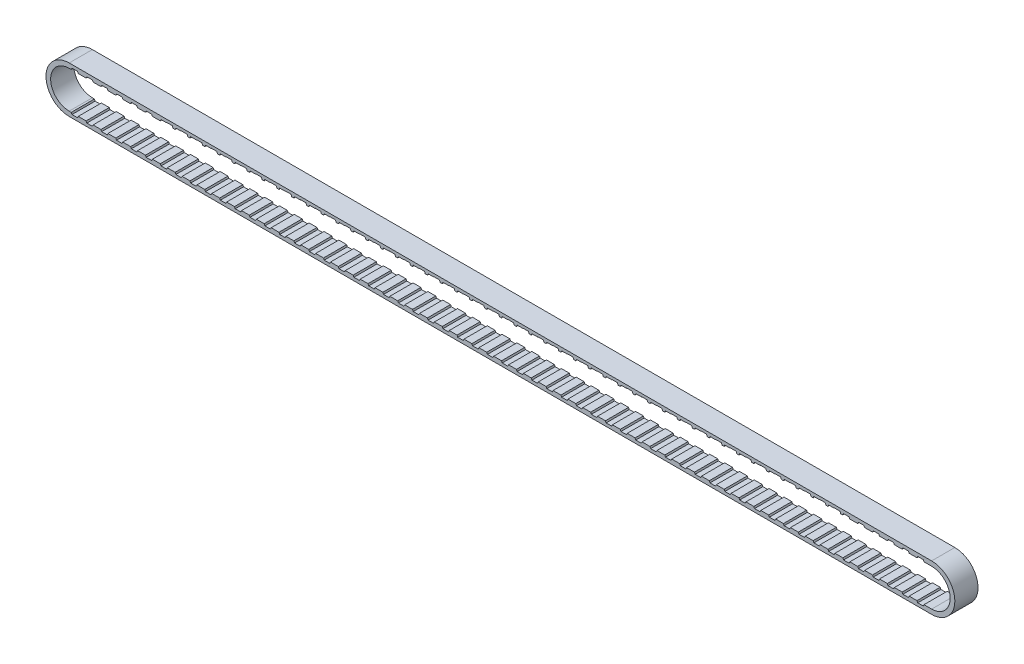
from build123d import *

# Parameters (mm, degrees)
BOSS_EXTRUDE1_DEPTH   = 6.35
CUT_EXTRUDE1_DEPTH    = 8.89
LPATTERN3_COUNT       = 50
LPATTERN3_PITCH       = 4.064
LPATTERN3_COL_COUNT   = 9
LPATTERN3_COL_PITCH   = 4.064
MIRROR3_COPY_1_DEPTH  = 8.89
MIRROR3_COPY_2_DEPTH  = 8.89
MIRROR3_COPY_3_DEPTH  = 8.89
MIRROR3_COPY_4_DEPTH  = 8.89
MIRROR3_COPY_5_DEPTH  = 8.89
MIRROR3_COPY_6_DEPTH  = 8.89
MIRROR3_COPY_7_DEPTH  = 8.89
MIRROR3_COPY_8_DEPTH  = 8.89
MIRROR3_COPY_9_DEPTH  = 8.89
MIRROR3_COPY_10_DEPTH = 8.89
MIRROR3_COPY_11_DEPTH = 8.89
MIRROR3_COPY_12_DEPTH = 8.89
MIRROR3_COPY_13_DEPTH = 8.89
MIRROR3_COPY_14_DEPTH = 8.89
MIRROR3_COPY_15_DEPTH = 8.89
MIRROR3_COPY_16_DEPTH = 8.89
MIRROR3_COPY_17_DEPTH = 8.89
MIRROR3_COPY_18_DEPTH = 8.89
MIRROR3_COPY_19_DEPTH = 8.89
MIRROR3_COPY_20_DEPTH = 8.89
MIRROR3_COPY_21_DEPTH = 8.89
MIRROR3_COPY_22_DEPTH = 8.89
MIRROR3_COPY_23_DEPTH = 8.89
MIRROR3_COPY_24_DEPTH = 8.89
MIRROR3_COPY_25_DEPTH = 8.89
MIRROR3_COPY_26_DEPTH = 8.89
MIRROR3_COPY_27_DEPTH = 8.89
MIRROR3_COPY_28_DEPTH = 8.89
MIRROR3_COPY_29_DEPTH = 8.89
MIRROR3_COPY_30_DEPTH = 8.89
MIRROR3_COPY_31_DEPTH = 8.89
MIRROR3_COPY_32_DEPTH = 8.89
MIRROR3_COPY_33_DEPTH = 8.89
MIRROR3_COPY_34_DEPTH = 8.89
MIRROR3_COPY_35_DEPTH = 8.89
MIRROR3_COPY_36_DEPTH = 8.89
MIRROR3_COPY_37_DEPTH = 8.89
MIRROR3_COPY_38_DEPTH = 8.89
MIRROR3_COPY_39_DEPTH = 8.89
MIRROR3_COPY_40_DEPTH = 8.89
MIRROR3_COPY_41_DEPTH = 8.89
MIRROR3_COPY_42_DEPTH = 8.89
MIRROR3_COPY_43_DEPTH = 8.89
MIRROR3_COPY_44_DEPTH = 8.89
MIRROR3_COPY_45_DEPTH = 8.89
MIRROR3_COPY_46_DEPTH = 8.89
MIRROR3_COPY_47_DEPTH = 8.89
MIRROR3_COPY_48_DEPTH = 8.89
MIRROR3_COPY_49_DEPTH = 8.89
MIRROR3_COPY_50_DEPTH = 8.89
MIRROR3_COPY_51_DEPTH = 8.89
MIRROR3_COPY_52_DEPTH = 8.89
MIRROR3_COPY_53_DEPTH = 8.89
MIRROR3_COPY_54_DEPTH = 8.89
MIRROR3_COPY_55_DEPTH = 8.89
MIRROR3_COPY_56_DEPTH = 8.89
MIRROR3_COPY_57_DEPTH = 8.89
CUT_EXTRUDE2_DEPTH    = 8.89
LPATTERN2_COUNT       = 46
LPATTERN2_PITCH       = 4.064


with BuildPart() as part:
    # Sketch1 → Boss-Extrude1 (new body)
    with BuildSketch(Plane.XY):
        with BuildLine():
            Line((-118.11, 6.35), (118.11, 6.35))
            ThreePointArc((118.11, 6.35), (124.46, 0), (118.11, -6.35))
            Line((118.11, -6.35), (-118.11, -6.35))
            ThreePointArc((-118.11, -6.35), (-124.46, 0), (-118.11, 6.35))
        make_face()
        with BuildLine():
            Line((-118.11, 5.08), (118.11, 5.08))
            ThreePointArc((118.11, 5.08), (123.19, 0), (118.11, -5.08))
            Line((118.11, -5.08), (-118.11, -5.08))
            ThreePointArc((-118.11, -5.08), (-123.19, 0), (-118.11, 5.08))
        make_face(mode=Mode.SUBTRACT)
    extrude(amount=-BOSS_EXTRUDE1_DEPTH)

    # Sketch2 → Cut-Extrude1 (cut)
    with BuildSketch(Plane.XY):
        Polygon((-85.09, -4.953), (-83.058, -4.953), (-83.312, -5.500699929), (-84.836, -5.500699929), align=None)
    cut_extrude1 = extrude(amount=-CUT_EXTRUDE1_DEPTH, mode=Mode.SUBTRACT)

    # LPattern3: Cut-Extrude1 ×50
    with Locations(*[(i * LPATTERN3_PITCH, 0, 0) for i in range(1, LPATTERN3_COUNT)]):
        add(cut_extrude1, mode=Mode.SUBTRACT)

    # LPattern3 col: Cut-Extrude1 ×9
    with Locations(*[(-i * LPATTERN3_COL_PITCH, 0, 0) for i in range(1, LPATTERN3_COL_COUNT)]):
        add(cut_extrude1, mode=Mode.SUBTRACT)

    # Mirror3: Cut-Extrude1 across plane
    add(cut_extrude1.mirror(Plane.ZX), mode=Mode.SUBTRACT)

    # Mirror3 copy 1 sketch → Mirror3 copy 1 (cut)
    with BuildSketch(Plane(origin=(4.064, 0, 0), x_dir=(1, 0, 0), z_dir=(0, 0, 1))):
        Polygon((-85.09, 4.953), (-83.058, 4.953), (-83.312, 5.500699929), (-84.836, 5.500699929), align=None)
    extrude(amount=-MIRROR3_COPY_1_DEPTH, mode=Mode.SUBTRACT)

    # Mirror3 copy 2 sketch → Mirror3 copy 2 (cut)
    with BuildSketch(Plane(origin=(8.128, 0, 0), x_dir=(1, 0, 0), z_dir=(0, 0, 1))):
        Polygon((-85.09, 4.953), (-83.058, 4.953), (-83.312, 5.500699929), (-84.836, 5.500699929), align=None)
    extrude(amount=-MIRROR3_COPY_2_DEPTH, mode=Mode.SUBTRACT)

    # Mirror3 copy 3 sketch → Mirror3 copy 3 (cut)
    with BuildSketch(Plane(origin=(12.192, 0, 0), x_dir=(1, 0, 0), z_dir=(0, 0, 1))):
        Polygon((-85.09, 4.953), (-83.058, 4.953), (-83.312, 5.500699929), (-84.836, 5.500699929), align=None)
    extrude(amount=-MIRROR3_COPY_3_DEPTH, mode=Mode.SUBTRACT)

    # Mirror3 copy 4 sketch → Mirror3 copy 4 (cut)
    with BuildSketch(Plane(origin=(16.256, 0, 0), x_dir=(1, 0, 0), z_dir=(0, 0, 1))):
        Polygon((-85.09, 4.953), (-83.058, 4.953), (-83.312, 5.500699929), (-84.836, 5.500699929), align=None)
    extrude(amount=-MIRROR3_COPY_4_DEPTH, mode=Mode.SUBTRACT)

    # Mirror3 copy 5 sketch → Mirror3 copy 5 (cut)
    with BuildSketch(Plane(origin=(20.32, 0, 0), x_dir=(1, 0, 0), z_dir=(0, 0, 1))):
        Polygon((-85.09, 4.953), (-83.058, 4.953), (-83.312, 5.500699929), (-84.836, 5.500699929), align=None)
    extrude(amount=-MIRROR3_COPY_5_DEPTH, mode=Mode.SUBTRACT)

    # Mirror3 copy 6 sketch → Mirror3 copy 6 (cut)
    with BuildSketch(Plane(origin=(24.384, 0, 0), x_dir=(1, 0, 0), z_dir=(0, 0, 1))):
        Polygon((-85.09, 4.953), (-83.058, 4.953), (-83.312, 5.500699929), (-84.836, 5.500699929), align=None)
    extrude(amount=-MIRROR3_COPY_6_DEPTH, mode=Mode.SUBTRACT)

    # Mirror3 copy 7 sketch → Mirror3 copy 7 (cut)
    with BuildSketch(Plane(origin=(28.448, 0, 0), x_dir=(1, 0, 0), z_dir=(0, 0, 1))):
        Polygon((-85.09, 4.953), (-83.058, 4.953), (-83.312, 5.500699929), (-84.836, 5.500699929), align=None)
    extrude(amount=-MIRROR3_COPY_7_DEPTH, mode=Mode.SUBTRACT)

    # Mirror3 copy 8 sketch → Mirror3 copy 8 (cut)
    with BuildSketch(Plane(origin=(32.512, 0, 0), x_dir=(1, 0, 0), z_dir=(0, 0, 1))):
        Polygon((-85.09, 4.953), (-83.058, 4.953), (-83.312, 5.500699929), (-84.836, 5.500699929), align=None)
    extrude(amount=-MIRROR3_COPY_8_DEPTH, mode=Mode.SUBTRACT)

    # Mirror3 copy 9 sketch → Mirror3 copy 9 (cut)
    with BuildSketch(Plane(origin=(36.576, 0, 0), x_dir=(1, 0, 0), z_dir=(0, 0, 1))):
        Polygon((-85.09, 4.953), (-83.058, 4.953), (-83.312, 5.500699929), (-84.836, 5.500699929), align=None)
    extrude(amount=-MIRROR3_COPY_9_DEPTH, mode=Mode.SUBTRACT)

    # Mirror3 copy 10 sketch → Mirror3 copy 10 (cut)
    with BuildSketch(Plane(origin=(40.64, 0, 0), x_dir=(1, 0, 0), z_dir=(0, 0, 1))):
        Polygon((-85.09, 4.953), (-83.058, 4.953), (-83.312, 5.500699929), (-84.836, 5.500699929), align=None)
    extrude(amount=-MIRROR3_COPY_10_DEPTH, mode=Mode.SUBTRACT)

    # Mirror3 copy 11 sketch → Mirror3 copy 11 (cut)
    with BuildSketch(Plane(origin=(44.704, 0, 0), x_dir=(1, 0, 0), z_dir=(0, 0, 1))):
        Polygon((-85.09, 4.953), (-83.058, 4.953), (-83.312, 5.500699929), (-84.836, 5.500699929), align=None)
    extrude(amount=-MIRROR3_COPY_11_DEPTH, mode=Mode.SUBTRACT)

    # Mirror3 copy 12 sketch → Mirror3 copy 12 (cut)
    with BuildSketch(Plane(origin=(48.768, 0, 0), x_dir=(1, 0, 0), z_dir=(0, 0, 1))):
        Polygon((-85.09, 4.953), (-83.058, 4.953), (-83.312, 5.500699929), (-84.836, 5.500699929), align=None)
    extrude(amount=-MIRROR3_COPY_12_DEPTH, mode=Mode.SUBTRACT)

    # Mirror3 copy 13 sketch → Mirror3 copy 13 (cut)
    with BuildSketch(Plane(origin=(52.832, 0, 0), x_dir=(1, 0, 0), z_dir=(0, 0, 1))):
        Polygon((-85.09, 4.953), (-83.058, 4.953), (-83.312, 5.500699929), (-84.836, 5.500699929), align=None)
    extrude(amount=-MIRROR3_COPY_13_DEPTH, mode=Mode.SUBTRACT)

    # Mirror3 copy 14 sketch → Mirror3 copy 14 (cut)
    with BuildSketch(Plane(origin=(56.896, 0, 0), x_dir=(1, 0, 0), z_dir=(0, 0, 1))):
        Polygon((-85.09, 4.953), (-83.058, 4.953), (-83.312, 5.500699929), (-84.836, 5.500699929), align=None)
    extrude(amount=-MIRROR3_COPY_14_DEPTH, mode=Mode.SUBTRACT)

    # Mirror3 copy 15 sketch → Mirror3 copy 15 (cut)
    with BuildSketch(Plane(origin=(60.96, 0, 0), x_dir=(1, 0, 0), z_dir=(0, 0, 1))):
        Polygon((-85.09, 4.953), (-83.058, 4.953), (-83.312, 5.500699929), (-84.836, 5.500699929), align=None)
    extrude(amount=-MIRROR3_COPY_15_DEPTH, mode=Mode.SUBTRACT)

    # Mirror3 copy 16 sketch → Mirror3 copy 16 (cut)
    with BuildSketch(Plane(origin=(65.024, 0, 0), x_dir=(1, 0, 0), z_dir=(0, 0, 1))):
        Polygon((-85.09, 4.953), (-83.058, 4.953), (-83.312, 5.500699929), (-84.836, 5.500699929), align=None)
    extrude(amount=-MIRROR3_COPY_16_DEPTH, mode=Mode.SUBTRACT)

    # Mirror3 copy 17 sketch → Mirror3 copy 17 (cut)
    with BuildSketch(Plane(origin=(69.088, 0, 0), x_dir=(1, 0, 0), z_dir=(0, 0, 1))):
        Polygon((-85.09, 4.953), (-83.058, 4.953), (-83.312, 5.500699929), (-84.836, 5.500699929), align=None)
    extrude(amount=-MIRROR3_COPY_17_DEPTH, mode=Mode.SUBTRACT)

    # Mirror3 copy 18 sketch → Mirror3 copy 18 (cut)
    with BuildSketch(Plane(origin=(73.152, 0, 0), x_dir=(1, 0, 0), z_dir=(0, 0, 1))):
        Polygon((-85.09, 4.953), (-83.058, 4.953), (-83.312, 5.500699929), (-84.836, 5.500699929), align=None)
    extrude(amount=-MIRROR3_COPY_18_DEPTH, mode=Mode.SUBTRACT)

    # Mirror3 copy 19 sketch → Mirror3 copy 19 (cut)
    with BuildSketch(Plane(origin=(77.216, 0, 0), x_dir=(1, 0, 0), z_dir=(0, 0, 1))):
        Polygon((-85.09, 4.953), (-83.058, 4.953), (-83.312, 5.500699929), (-84.836, 5.500699929), align=None)
    extrude(amount=-MIRROR3_COPY_19_DEPTH, mode=Mode.SUBTRACT)

    # Mirror3 copy 20 sketch → Mirror3 copy 20 (cut)
    with BuildSketch(Plane(origin=(81.28, 0, 0), x_dir=(1, 0, 0), z_dir=(0, 0, 1))):
        Polygon((-85.09, 4.953), (-83.058, 4.953), (-83.312, 5.500699929), (-84.836, 5.500699929), align=None)
    extrude(amount=-MIRROR3_COPY_20_DEPTH, mode=Mode.SUBTRACT)

    # Mirror3 copy 21 sketch → Mirror3 copy 21 (cut)
    with BuildSketch(Plane(origin=(85.344, 0, 0), x_dir=(1, 0, 0), z_dir=(0, 0, 1))):
        Polygon((-85.09, 4.953), (-83.058, 4.953), (-83.312, 5.500699929), (-84.836, 5.500699929), align=None)
    extrude(amount=-MIRROR3_COPY_21_DEPTH, mode=Mode.SUBTRACT)

    # Mirror3 copy 22 sketch → Mirror3 copy 22 (cut)
    with BuildSketch(Plane(origin=(89.408, 0, 0), x_dir=(1, 0, 0), z_dir=(0, 0, 1))):
        Polygon((-85.09, 4.953), (-83.058, 4.953), (-83.312, 5.500699929), (-84.836, 5.500699929), align=None)
    extrude(amount=-MIRROR3_COPY_22_DEPTH, mode=Mode.SUBTRACT)

    # Mirror3 copy 23 sketch → Mirror3 copy 23 (cut)
    with BuildSketch(Plane(origin=(93.472, 0, 0), x_dir=(1, 0, 0), z_dir=(0, 0, 1))):
        Polygon((-85.09, 4.953), (-83.058, 4.953), (-83.312, 5.500699929), (-84.836, 5.500699929), align=None)
    extrude(amount=-MIRROR3_COPY_23_DEPTH, mode=Mode.SUBTRACT)

    # Mirror3 copy 24 sketch → Mirror3 copy 24 (cut)
    with BuildSketch(Plane(origin=(97.536, 0, 0), x_dir=(1, 0, 0), z_dir=(0, 0, 1))):
        Polygon((-85.09, 4.953), (-83.058, 4.953), (-83.312, 5.500699929), (-84.836, 5.500699929), align=None)
    extrude(amount=-MIRROR3_COPY_24_DEPTH, mode=Mode.SUBTRACT)

    # Mirror3 copy 25 sketch → Mirror3 copy 25 (cut)
    with BuildSketch(Plane(origin=(101.6, 0, 0), x_dir=(1, 0, 0), z_dir=(0, 0, 1))):
        Polygon((-85.09, 4.953), (-83.058, 4.953), (-83.312, 5.500699929), (-84.836, 5.500699929), align=None)
    extrude(amount=-MIRROR3_COPY_25_DEPTH, mode=Mode.SUBTRACT)

    # Mirror3 copy 26 sketch → Mirror3 copy 26 (cut)
    with BuildSketch(Plane(origin=(105.664, 0, 0), x_dir=(1, 0, 0), z_dir=(0, 0, 1))):
        Polygon((-85.09, 4.953), (-83.058, 4.953), (-83.312, 5.500699929), (-84.836, 5.500699929), align=None)
    extrude(amount=-MIRROR3_COPY_26_DEPTH, mode=Mode.SUBTRACT)

    # Mirror3 copy 27 sketch → Mirror3 copy 27 (cut)
    with BuildSketch(Plane(origin=(109.728, 0, 0), x_dir=(1, 0, 0), z_dir=(0, 0, 1))):
        Polygon((-85.09, 4.953), (-83.058, 4.953), (-83.312, 5.500699929), (-84.836, 5.500699929), align=None)
    extrude(amount=-MIRROR3_COPY_27_DEPTH, mode=Mode.SUBTRACT)

    # Mirror3 copy 28 sketch → Mirror3 copy 28 (cut)
    with BuildSketch(Plane(origin=(113.792, 0, 0), x_dir=(1, 0, 0), z_dir=(0, 0, 1))):
        Polygon((-85.09, 4.953), (-83.058, 4.953), (-83.312, 5.500699929), (-84.836, 5.500699929), align=None)
    extrude(amount=-MIRROR3_COPY_28_DEPTH, mode=Mode.SUBTRACT)

    # Mirror3 copy 29 sketch → Mirror3 copy 29 (cut)
    with BuildSketch(Plane(origin=(117.856, 0, 0), x_dir=(1, 0, 0), z_dir=(0, 0, 1))):
        Polygon((-85.09, 4.953), (-83.058, 4.953), (-83.312, 5.500699929), (-84.836, 5.500699929), align=None)
    extrude(amount=-MIRROR3_COPY_29_DEPTH, mode=Mode.SUBTRACT)

    # Mirror3 copy 30 sketch → Mirror3 copy 30 (cut)
    with BuildSketch(Plane(origin=(121.92, 0, 0), x_dir=(1, 0, 0), z_dir=(0, 0, 1))):
        Polygon((-85.09, 4.953), (-83.058, 4.953), (-83.312, 5.500699929), (-84.836, 5.500699929), align=None)
    extrude(amount=-MIRROR3_COPY_30_DEPTH, mode=Mode.SUBTRACT)

    # Mirror3 copy 31 sketch → Mirror3 copy 31 (cut)
    with BuildSketch(Plane(origin=(125.984, 0, 0), x_dir=(1, 0, 0), z_dir=(0, 0, 1))):
        Polygon((-85.09, 4.953), (-83.058, 4.953), (-83.312, 5.500699929), (-84.836, 5.500699929), align=None)
    extrude(amount=-MIRROR3_COPY_31_DEPTH, mode=Mode.SUBTRACT)

    # Mirror3 copy 32 sketch → Mirror3 copy 32 (cut)
    with BuildSketch(Plane(origin=(130.048, 0, 0), x_dir=(1, 0, 0), z_dir=(0, 0, 1))):
        Polygon((-85.09, 4.953), (-83.058, 4.953), (-83.312, 5.500699929), (-84.836, 5.500699929), align=None)
    extrude(amount=-MIRROR3_COPY_32_DEPTH, mode=Mode.SUBTRACT)

    # Mirror3 copy 33 sketch → Mirror3 copy 33 (cut)
    with BuildSketch(Plane(origin=(134.112, 0, 0), x_dir=(1, 0, 0), z_dir=(0, 0, 1))):
        Polygon((-85.09, 4.953), (-83.058, 4.953), (-83.312, 5.500699929), (-84.836, 5.500699929), align=None)
    extrude(amount=-MIRROR3_COPY_33_DEPTH, mode=Mode.SUBTRACT)

    # Mirror3 copy 34 sketch → Mirror3 copy 34 (cut)
    with BuildSketch(Plane(origin=(138.176, 0, 0), x_dir=(1, 0, 0), z_dir=(0, 0, 1))):
        Polygon((-85.09, 4.953), (-83.058, 4.953), (-83.312, 5.500699929), (-84.836, 5.500699929), align=None)
    extrude(amount=-MIRROR3_COPY_34_DEPTH, mode=Mode.SUBTRACT)

    # Mirror3 copy 35 sketch → Mirror3 copy 35 (cut)
    with BuildSketch(Plane(origin=(142.24, 0, 0), x_dir=(1, 0, 0), z_dir=(0, 0, 1))):
        Polygon((-85.09, 4.953), (-83.058, 4.953), (-83.312, 5.500699929), (-84.836, 5.500699929), align=None)
    extrude(amount=-MIRROR3_COPY_35_DEPTH, mode=Mode.SUBTRACT)

    # Mirror3 copy 36 sketch → Mirror3 copy 36 (cut)
    with BuildSketch(Plane(origin=(146.304, 0, 0), x_dir=(1, 0, 0), z_dir=(0, 0, 1))):
        Polygon((-85.09, 4.953), (-83.058, 4.953), (-83.312, 5.500699929), (-84.836, 5.500699929), align=None)
    extrude(amount=-MIRROR3_COPY_36_DEPTH, mode=Mode.SUBTRACT)

    # Mirror3 copy 37 sketch → Mirror3 copy 37 (cut)
    with BuildSketch(Plane(origin=(150.368, 0, 0), x_dir=(1, 0, 0), z_dir=(0, 0, 1))):
        Polygon((-85.09, 4.953), (-83.058, 4.953), (-83.312, 5.500699929), (-84.836, 5.500699929), align=None)
    extrude(amount=-MIRROR3_COPY_37_DEPTH, mode=Mode.SUBTRACT)

    # Mirror3 copy 38 sketch → Mirror3 copy 38 (cut)
    with BuildSketch(Plane(origin=(154.432, 0, 0), x_dir=(1, 0, 0), z_dir=(0, 0, 1))):
        Polygon((-85.09, 4.953), (-83.058, 4.953), (-83.312, 5.500699929), (-84.836, 5.500699929), align=None)
    extrude(amount=-MIRROR3_COPY_38_DEPTH, mode=Mode.SUBTRACT)

    # Mirror3 copy 39 sketch → Mirror3 copy 39 (cut)
    with BuildSketch(Plane(origin=(158.496, 0, 0), x_dir=(1, 0, 0), z_dir=(0, 0, 1))):
        Polygon((-85.09, 4.953), (-83.058, 4.953), (-83.312, 5.500699929), (-84.836, 5.500699929), align=None)
    extrude(amount=-MIRROR3_COPY_39_DEPTH, mode=Mode.SUBTRACT)

    # Mirror3 copy 40 sketch → Mirror3 copy 40 (cut)
    with BuildSketch(Plane(origin=(162.56, 0, 0), x_dir=(1, 0, 0), z_dir=(0, 0, 1))):
        Polygon((-85.09, 4.953), (-83.058, 4.953), (-83.312, 5.500699929), (-84.836, 5.500699929), align=None)
    extrude(amount=-MIRROR3_COPY_40_DEPTH, mode=Mode.SUBTRACT)

    # Mirror3 copy 41 sketch → Mirror3 copy 41 (cut)
    with BuildSketch(Plane(origin=(166.624, 0, 0), x_dir=(1, 0, 0), z_dir=(0, 0, 1))):
        Polygon((-85.09, 4.953), (-83.058, 4.953), (-83.312, 5.500699929), (-84.836, 5.500699929), align=None)
    extrude(amount=-MIRROR3_COPY_41_DEPTH, mode=Mode.SUBTRACT)

    # Mirror3 copy 42 sketch → Mirror3 copy 42 (cut)
    with BuildSketch(Plane(origin=(170.688, 0, 0), x_dir=(1, 0, 0), z_dir=(0, 0, 1))):
        Polygon((-85.09, 4.953), (-83.058, 4.953), (-83.312, 5.500699929), (-84.836, 5.500699929), align=None)
    extrude(amount=-MIRROR3_COPY_42_DEPTH, mode=Mode.SUBTRACT)

    # Mirror3 copy 43 sketch → Mirror3 copy 43 (cut)
    with BuildSketch(Plane(origin=(174.752, 0, 0), x_dir=(1, 0, 0), z_dir=(0, 0, 1))):
        Polygon((-85.09, 4.953), (-83.058, 4.953), (-83.312, 5.500699929), (-84.836, 5.500699929), align=None)
    extrude(amount=-MIRROR3_COPY_43_DEPTH, mode=Mode.SUBTRACT)

    # Mirror3 copy 44 sketch → Mirror3 copy 44 (cut)
    with BuildSketch(Plane(origin=(178.816, 0, 0), x_dir=(1, 0, 0), z_dir=(0, 0, 1))):
        Polygon((-85.09, 4.953), (-83.058, 4.953), (-83.312, 5.500699929), (-84.836, 5.500699929), align=None)
    extrude(amount=-MIRROR3_COPY_44_DEPTH, mode=Mode.SUBTRACT)

    # Mirror3 copy 45 sketch → Mirror3 copy 45 (cut)
    with BuildSketch(Plane(origin=(182.88, 0, 0), x_dir=(1, 0, 0), z_dir=(0, 0, 1))):
        Polygon((-85.09, 4.953), (-83.058, 4.953), (-83.312, 5.500699929), (-84.836, 5.500699929), align=None)
    extrude(amount=-MIRROR3_COPY_45_DEPTH, mode=Mode.SUBTRACT)

    # Mirror3 copy 46 sketch → Mirror3 copy 46 (cut)
    with BuildSketch(Plane(origin=(186.944, 0, 0), x_dir=(1, 0, 0), z_dir=(0, 0, 1))):
        Polygon((-85.09, 4.953), (-83.058, 4.953), (-83.312, 5.500699929), (-84.836, 5.500699929), align=None)
    extrude(amount=-MIRROR3_COPY_46_DEPTH, mode=Mode.SUBTRACT)

    # Mirror3 copy 47 sketch → Mirror3 copy 47 (cut)
    with BuildSketch(Plane(origin=(191.008, 0, 0), x_dir=(1, 0, 0), z_dir=(0, 0, 1))):
        Polygon((-85.09, 4.953), (-83.058, 4.953), (-83.312, 5.500699929), (-84.836, 5.500699929), align=None)
    extrude(amount=-MIRROR3_COPY_47_DEPTH, mode=Mode.SUBTRACT)

    # Mirror3 copy 48 sketch → Mirror3 copy 48 (cut)
    with BuildSketch(Plane(origin=(195.072, 0, 0), x_dir=(1, 0, 0), z_dir=(0, 0, 1))):
        Polygon((-85.09, 4.953), (-83.058, 4.953), (-83.312, 5.500699929), (-84.836, 5.500699929), align=None)
    extrude(amount=-MIRROR3_COPY_48_DEPTH, mode=Mode.SUBTRACT)

    # Mirror3 copy 49 sketch → Mirror3 copy 49 (cut)
    with BuildSketch(Plane(origin=(199.136, 0, 0), x_dir=(1, 0, 0), z_dir=(0, 0, 1))):
        Polygon((-85.09, 4.953), (-83.058, 4.953), (-83.312, 5.500699929), (-84.836, 5.500699929), align=None)
    extrude(amount=-MIRROR3_COPY_49_DEPTH, mode=Mode.SUBTRACT)

    # Mirror3 copy 50 sketch → Mirror3 copy 50 (cut)
    with BuildSketch(Plane(origin=(-4.064, 0, 0), x_dir=(1, 0, 0), z_dir=(0, 0, 1))):
        Polygon((-85.09, 4.953), (-83.058, 4.953), (-83.312, 5.500699929), (-84.836, 5.500699929), align=None)
    extrude(amount=-MIRROR3_COPY_50_DEPTH, mode=Mode.SUBTRACT)

    # Mirror3 copy 51 sketch → Mirror3 copy 51 (cut)
    with BuildSketch(Plane(origin=(-8.128, 0, 0), x_dir=(1, 0, 0), z_dir=(0, 0, 1))):
        Polygon((-85.09, 4.953), (-83.058, 4.953), (-83.312, 5.500699929), (-84.836, 5.500699929), align=None)
    extrude(amount=-MIRROR3_COPY_51_DEPTH, mode=Mode.SUBTRACT)

    # Mirror3 copy 52 sketch → Mirror3 copy 52 (cut)
    with BuildSketch(Plane(origin=(-12.192, 0, 0), x_dir=(1, 0, 0), z_dir=(0, 0, 1))):
        Polygon((-85.09, 4.953), (-83.058, 4.953), (-83.312, 5.500699929), (-84.836, 5.500699929), align=None)
    extrude(amount=-MIRROR3_COPY_52_DEPTH, mode=Mode.SUBTRACT)

    # Mirror3 copy 53 sketch → Mirror3 copy 53 (cut)
    with BuildSketch(Plane(origin=(-16.256, 0, 0), x_dir=(1, 0, 0), z_dir=(0, 0, 1))):
        Polygon((-85.09, 4.953), (-83.058, 4.953), (-83.312, 5.500699929), (-84.836, 5.500699929), align=None)
    extrude(amount=-MIRROR3_COPY_53_DEPTH, mode=Mode.SUBTRACT)

    # Mirror3 copy 54 sketch → Mirror3 copy 54 (cut)
    with BuildSketch(Plane(origin=(-20.32, 0, 0), x_dir=(1, 0, 0), z_dir=(0, 0, 1))):
        Polygon((-85.09, 4.953), (-83.058, 4.953), (-83.312, 5.500699929), (-84.836, 5.500699929), align=None)
    extrude(amount=-MIRROR3_COPY_54_DEPTH, mode=Mode.SUBTRACT)

    # Mirror3 copy 55 sketch → Mirror3 copy 55 (cut)
    with BuildSketch(Plane(origin=(-24.384, 0, 0), x_dir=(1, 0, 0), z_dir=(0, 0, 1))):
        Polygon((-85.09, 4.953), (-83.058, 4.953), (-83.312, 5.500699929), (-84.836, 5.500699929), align=None)
    extrude(amount=-MIRROR3_COPY_55_DEPTH, mode=Mode.SUBTRACT)

    # Mirror3 copy 56 sketch → Mirror3 copy 56 (cut)
    with BuildSketch(Plane(origin=(-28.448, 0, 0), x_dir=(1, 0, 0), z_dir=(0, 0, 1))):
        Polygon((-85.09, 4.953), (-83.058, 4.953), (-83.312, 5.500699929), (-84.836, 5.500699929), align=None)
    extrude(amount=-MIRROR3_COPY_56_DEPTH, mode=Mode.SUBTRACT)

    # Mirror3 copy 57 sketch → Mirror3 copy 57 (cut)
    with BuildSketch(Plane(origin=(-32.512, 0, 0), x_dir=(1, 0, 0), z_dir=(0, 0, 1))):
        Polygon((-85.09, 4.953), (-83.058, 4.953), (-83.312, 5.500699929), (-84.836, 5.500699929), align=None)
    extrude(amount=-MIRROR3_COPY_57_DEPTH, mode=Mode.SUBTRACT)

    # Sketch3 → Cut-Extrude2 (cut)
    with BuildSketch(Plane.XY):
        Polygon((-91.645907376, 4.953), (-89.613907376, 4.953), (-89.867907376, 5.588), (-91.391907376, 5.588), align=None)
    cut_extrude2 = extrude(amount=-CUT_EXTRUDE2_DEPTH, mode=Mode.SUBTRACT)

    # LPattern2: Cut-Extrude2 ×46
    with Locations(*[(i * LPATTERN2_PITCH, 0, 0) for i in range(1, LPATTERN2_COUNT)]):
        add(cut_extrude2, mode=Mode.SUBTRACT)


solid = part.part
